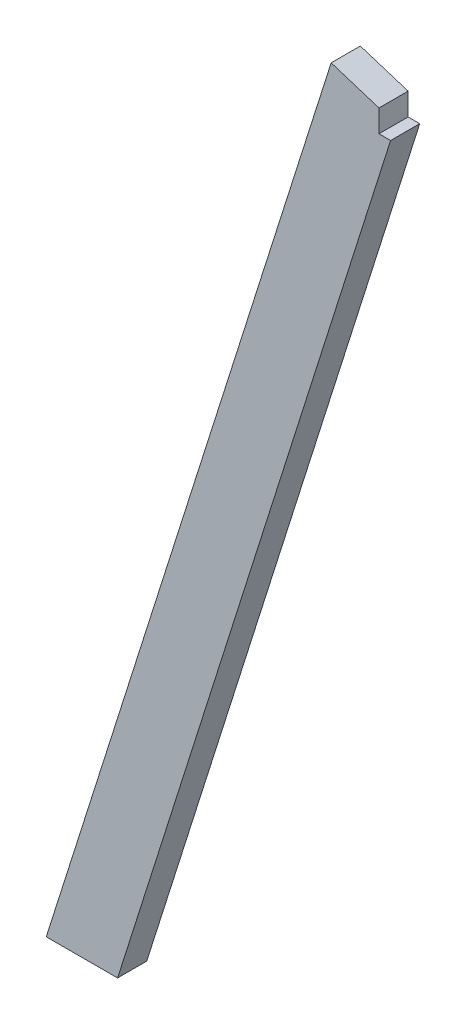
from build123d import *

# Parameters (mm, degrees)
BOSS_EXTRUDE1_DEPTH = 38.1
CUT_EXTRUDE1_DEPTH  = 39.1


with BuildPart() as part:
    # Sketch2 → Boss-Extrude1 (new body)
    with BuildSketch(Plane.XY):
        Polygon((0, 0), (93.254232292, 0), (457.2, 1148.849141334), (372.450924213, 1175.696937394), align=None)
    extrude(amount=BOSS_EXTRUDE1_DEPTH)

    # Sketch3 → Cut-Extrude1 (cut, through all)
    with BuildSketch(Plane.XY.offset(38.1)):
        Polygon((434.975, 1126.624141334), (450.159306495, 1126.624141334), (457.2, 1148.849141334), (434.975, 1155.889834839), align=None)
    extrude(amount=-CUT_EXTRUDE1_DEPTH, mode=Mode.SUBTRACT)


solid = part.part
